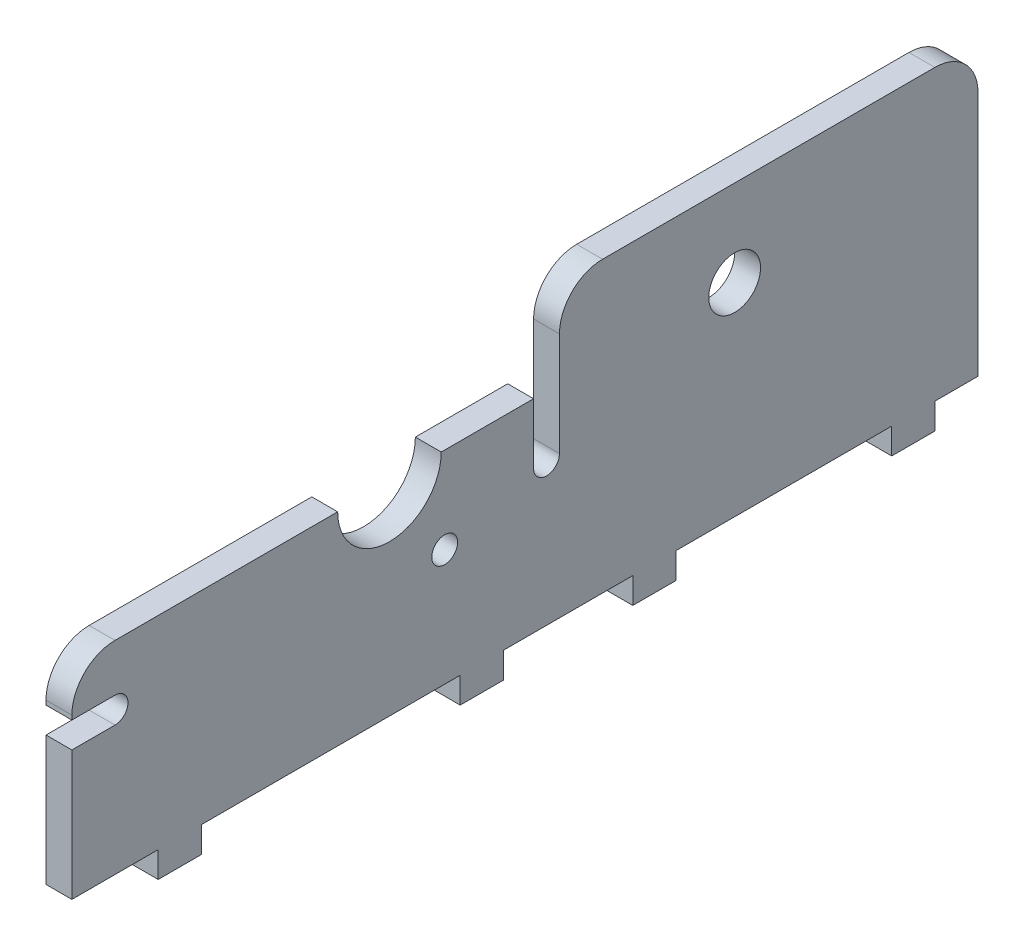
from build123d import *

# Parameters (mm, degrees)
SKETCH1_W           = 105
SKETCH1_H           = 23.5
BOSS_EXTRUDE1_DEPTH = 3
SKETCH2_R           = 6
SKETCH2_R_2         = 1.5
CUT_EXTRUDE1_DEPTH  = 4
CUT_EXTRUDE2_DEPTH  = 4
SKETCH4_W           = 3
SKETCH4_H           = 5
BOSS_EXTRUDE2_DEPTH = 3
CUT_EXTRUDE4_DEPTH  = 4
SKETCH5_W           = 3
SKETCH5_H           = 5
BOSS_EXTRUDE3_DEPTH = 3
SKETCH9_W           = 3
SKETCH9_H           = 48.5
BOSS_EXTRUDE5_DEPTH = 10
SKETCH10_R          = 3
CUT_EXTRUDE5_DEPTH  = 4
FILLET5_R           = 5


with BuildPart() as part:
    # Sketch1 → Boss-Extrude1 (new body)
    with BuildSketch(Plane(origin=(0, 0, 0), x_dir=(0, 0, -1), z_dir=(1, 0, 0))):
        with Locations((22.5, 11.75)):
            Rectangle(SKETCH1_W, SKETCH1_H)
    extrude(amount=BOSS_EXTRUDE1_DEPTH)

    # Sketch2 → Cut-Extrude1 (cut, through all)
    with BuildSketch(Plane(origin=(3, 0, 0), x_dir=(0, 0, -1), z_dir=(1, 0, 0))):
        with Locations((6.8, 23.5)):
            Circle(SKETCH2_R)
        with Locations((13.2, 13.5)):
            Circle(SKETCH2_R_2)
    extrude(amount=-CUT_EXTRUDE1_DEPTH, mode=Mode.SUBTRACT)

    # Sketch3 → Cut-Extrude2 (cut, through all)
    with BuildSketch(Plane(origin=(3, 0, 0), x_dir=(0, 0, -1), z_dir=(1, 0, 0))):
        with BuildLine():
            Line((-25, 15), (-30, 15))
            Line((-30, 15), (-30, 18))
            Line((-30, 18), (-25, 18))
            ThreePointArc((-25, 18), (-23.5, 16.5), (-25, 15))
        make_face()
    extrude(amount=-CUT_EXTRUDE2_DEPTH, mode=Mode.SUBTRACT)

    # Sketch4 → Boss-Extrude2 (add)
    with BuildSketch(Plane.XZ):
        with Locations((1.5, 17.5)):
            Rectangle(SKETCH4_W, SKETCH4_H)
    boss_extrude2 = extrude(amount=BOSS_EXTRUDE2_DEPTH)

    # Mirror4: Boss-Extrude2 across plane
    add(boss_extrude2.mirror(Plane.XY))

    # Sketch8 → Cut-Extrude4 (cut, through all)
    with BuildSketch(Plane(origin=(3, 0, 0), x_dir=(0, 0, -1), z_dir=(1, 0, 0))):
        with BuildLine():
            Line((23.5, 16.5), (23.5, 23.5))
            Line((23.5, 23.5), (26.5, 23.5))
            Line((26.5, 23.5), (26.5, 16.5))
            ThreePointArc((26.5, 16.5), (25, 15), (23.5, 16.5))
        make_face()
    extrude(amount=-CUT_EXTRUDE4_DEPTH, mode=Mode.SUBTRACT)

    # Sketch5 → Boss-Extrude3 (add)
    with BuildSketch(Plane.XZ):
        with Locations((1.5, -37.5)):
            Rectangle(SKETCH5_W, SKETCH5_H)
        with Locations((1.5, -67.5)):
            Rectangle(SKETCH5_W, SKETCH5_H)
    extrude(amount=BOSS_EXTRUDE3_DEPTH)

    # Sketch9 → Boss-Extrude5 (add)
    with BuildSketch(Plane(origin=(0, 23.5, 0), x_dir=(1, 0, 0), z_dir=(0, 1, 0))):
        with Locations((1.5, 50.75)):
            Rectangle(SKETCH9_W, SKETCH9_H)
    extrude(amount=BOSS_EXTRUDE5_DEPTH)

    # Sketch10 → Cut-Extrude5 (cut, through all)
    with BuildSketch(Plane(origin=(3, 0, 0), x_dir=(0, 0, -1), z_dir=(1, 0, 0))):
        with Locations((46.8, 23.5)):
            Circle(SKETCH10_R)
    extrude(amount=-CUT_EXTRUDE5_DEPTH, mode=Mode.SUBTRACT)

    # Fillet5
    fillet5_edges = [part.edges().sort_by_distance(p)[0] for p in [
        (1.5, 33.5, -26.5),
        (1.5, 33.5, -75),
        (1.5, 23.5, 30),
    ]]
    fillet(fillet5_edges, radius=FILLET5_R)


solid = part.part
